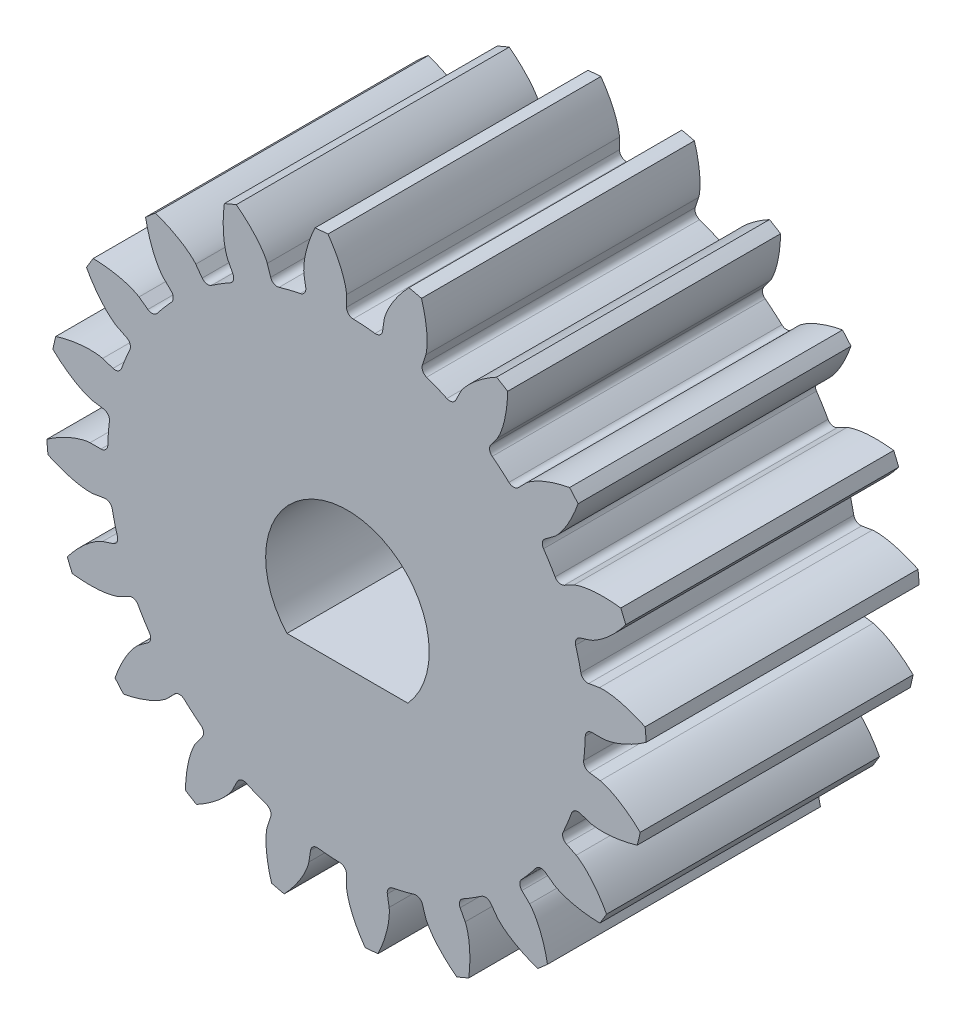
from build123d import *

# Parameters (mm, degrees)
BOSS_EXTRUDE3_DEPTH       = 5
FILLET1_R                 = 0.125
CIRPATTERN8_COUNT         = 20
CIRPATTERN8_COPY_1_DEPTH  = 5
CIRPATTERN8_COPY_2_DEPTH  = 5
CIRPATTERN8_COPY_3_DEPTH  = 5
CIRPATTERN8_COPY_4_DEPTH  = 5
CIRPATTERN8_COPY_5_DEPTH  = 5
CIRPATTERN8_COPY_6_DEPTH  = 5
CIRPATTERN8_COPY_7_DEPTH  = 5
CIRPATTERN8_COPY_8_DEPTH  = 5
CIRPATTERN8_COPY_9_DEPTH  = 5
CIRPATTERN8_COPY_10_DEPTH = 5
CIRPATTERN8_COPY_11_DEPTH = 5
CIRPATTERN8_COPY_12_DEPTH = 5
CIRPATTERN8_COPY_13_DEPTH = 5
CIRPATTERN8_COPY_14_DEPTH = 5
CIRPATTERN8_COPY_15_DEPTH = 5
CIRPATTERN8_COPY_16_DEPTH = 5
CIRPATTERN8_COPY_17_DEPTH = 5
CIRPATTERN8_COPY_18_DEPTH = 5
CIRPATTERN8_COPY_19_DEPTH = 5
FILLET1_OF_CIRPATTERN8_R  = 0.125
CUT_EXTRUDE2_DEPTH        = 6.0000001
TAGLIO_ESTRUSIONE2_DEPTH  = 0.3


with BuildPart() as part:
    # Sketch1 → Boss-Extrude3 (new body)
    with BuildSketch(Plane.XY):
        with BuildLine():
            Line((4.375, 0), (4.698463104, 0))
            add(Edge.make_bspline(
                [(4.698463104, 0), (4.701936693, 7.3507e-05), (4.711671667, 0.000507155), (4.730035453, 0.002224847), (4.759876783, 0.006298442), (4.79766874, 0.013349079), (4.846157716, 0.02458424), (4.902733795, 0.040529055), (4.964229103, 0.060864675), (5.030289125, 0.085989187), (5.095362708, 0.113680418), (5.159425932, 0.143715794), (5.222425493, 0.175792819), (5.297691656, 0.217156604), (5.372506382, 0.26189353), (5.430958883, 0.299810406), (5.473798774, 0.329094693), (5.489479816, 0.340016693)],
                knots=[0, 0, 0, 0, 0, 0.005376748, 0.015083688, 0.02853182, 0.046610139, 0.064854849, 0.092110525, 0.119476175, 0.146842495, 0.174208853, 0.201574955, 0.228941013, 0.256307345, 0.307035032, 0.336624535, 0.336624535, 0.336624535, 0.336624535, 0.336624535], degree=4))
            ThreePointArc((5.489479816, 0.340016693), (5.485490898, 0.399236281), (5.480863148, 0.458409374))
            Line((5.480863148, 0.458409374), (4.359777504, 0.36464382))
            ThreePointArc((4.359777504, 0.36464382), (4.371192719, 0.182480711), (4.375, 0))
        make_face()
        with BuildLine():
            ThreePointArc((-4.359777504, -0.36464382), (0.182480711, -4.371192719), (4.375, 0))
            ThreePointArc((4.375, 0), (4.371192719, 0.182480711), (4.359777504, 0.36464382))
            Line((4.359777504, 0.36464382), (-4.359777504, -0.36464382))
        make_face()
        with BuildLine():
            Line((-4.359777504, -0.36464382), (4.359777504, 0.36464382))
            ThreePointArc((4.359777504, 0.36464382), (-0.36464382, 4.359777504), (-4.359777504, -0.36464382))
        make_face()
    boss_extrude3 = extrude(amount=BOSS_EXTRUDE3_DEPTH)

    # Mirror2: Boss-Extrude3 across plane
    add(boss_extrude3.mirror(Plane(origin=(0, 0, 5), x_dir=(0, 0, 1), z_dir=(0.083347159, -0.996520572, 0))))

    # Fillet1
    fillet1_edges = [part.edges().sort_by_distance(p)[0] for p in [
        (4.375, 0, 2.5),
        (4.314215947, 0.726750137, 2.5),
    ]]
    fillet(fillet1_edges, radius=FILLET1_R)

    # CirPattern8: Boss-Extrude3 ×20 about axis
    cirpattern8_axis = Axis((0, 0, 5), (0, 0, -1))
    for i in range(1, CIRPATTERN8_COUNT):
        add(boss_extrude3.rotate(cirpattern8_axis, i * 360 / CIRPATTERN8_COUNT))

    # CirPattern8 copy 1 sketch → CirPattern8 copy 1 (add)
    with BuildSketch(Plane(origin=(0, 0, 0), x_dir=(0.989175162, -0.146739564, 0), z_dir=(0, 0, 1))):
        with BuildLine():
            Line((4.375, 0), (4.698463104, 0))
            add(Edge.make_bspline(
                [(4.698463104, 0), (4.701936693, -7.3507e-05), (4.711671667, -0.000507155), (4.730035453, -0.002224847), (4.759876783, -0.006298442), (4.79766874, -0.013349079), (4.846157716, -0.02458424), (4.902733795, -0.040529055), (4.964229103, -0.060864675), (5.030289125, -0.085989187), (5.095362708, -0.113680418), (5.159425932, -0.143715794), (5.222425493, -0.175792819), (5.297691656, -0.217156604), (5.372506382, -0.26189353), (5.430958883, -0.299810406), (5.473798774, -0.329094693), (5.489479816, -0.340016693)],
                knots=[0, 0, 0, 0, 0, 0.005376748, 0.015083688, 0.02853182, 0.046610139, 0.064854849, 0.092110525, 0.119476175, 0.146842495, 0.174208853, 0.201574955, 0.228941013, 0.256307345, 0.307035032, 0.336624535, 0.336624535, 0.336624535, 0.336624535, 0.336624535], degree=4))
            ThreePointArc((5.489479816, -0.340016693), (5.485490898, -0.399236281), (5.480863148, -0.458409374))
            Line((5.480863148, -0.458409374), (4.359777504, -0.36464382))
            ThreePointArc((4.359777504, -0.36464382), (4.371192719, -0.182480711), (4.375, 0))
        make_face()
        with BuildLine():
            ThreePointArc((-4.359777504, 0.36464382), (0.182480711, 4.371192719), (4.375, 0))
            ThreePointArc((4.375, 0), (4.371192719, -0.182480711), (4.359777504, -0.36464382))
            Line((4.359777504, -0.36464382), (-4.359777504, 0.36464382))
        make_face()
        with BuildLine():
            Line((-4.359777504, 0.36464382), (4.359777504, -0.36464382))
            ThreePointArc((4.359777504, -0.36464382), (-0.36464382, -4.359777504), (-4.359777504, 0.36464382))
        make_face()
    extrude(amount=CIRPATTERN8_COPY_1_DEPTH)

    # CirPattern8 copy 2 sketch → CirPattern8 copy 2 (add)
    with BuildSketch(Plane(origin=(0, 0, 0), x_dir=(0.895416464, -0.445229554, 0), z_dir=(0, 0, 1))):
        with BuildLine():
            Line((4.375, 0), (4.698463104, 0))
            add(Edge.make_bspline(
                [(4.698463104, 0), (4.701936693, -7.3507e-05), (4.711671667, -0.000507155), (4.730035453, -0.002224847), (4.759876783, -0.006298442), (4.79766874, -0.013349079), (4.846157716, -0.02458424), (4.902733795, -0.040529055), (4.964229103, -0.060864675), (5.030289125, -0.085989187), (5.095362708, -0.113680418), (5.159425932, -0.143715794), (5.222425493, -0.175792819), (5.297691656, -0.217156604), (5.372506382, -0.26189353), (5.430958883, -0.299810406), (5.473798774, -0.329094693), (5.489479816, -0.340016693)],
                knots=[0, 0, 0, 0, 0, 0.005376748, 0.015083688, 0.02853182, 0.046610139, 0.064854849, 0.092110525, 0.119476175, 0.146842495, 0.174208853, 0.201574955, 0.228941013, 0.256307345, 0.307035032, 0.336624535, 0.336624535, 0.336624535, 0.336624535, 0.336624535], degree=4))
            ThreePointArc((5.489479816, -0.340016693), (5.485490898, -0.399236281), (5.480863148, -0.458409374))
            Line((5.480863148, -0.458409374), (4.359777504, -0.36464382))
            ThreePointArc((4.359777504, -0.36464382), (4.371192719, -0.182480711), (4.375, 0))
        make_face()
        with BuildLine():
            ThreePointArc((-4.359777504, 0.36464382), (0.182480711, 4.371192719), (4.375, 0))
            ThreePointArc((4.375, 0), (4.371192719, -0.182480711), (4.359777504, -0.36464382))
            Line((4.359777504, -0.36464382), (-4.359777504, 0.36464382))
        make_face()
        with BuildLine():
            Line((-4.359777504, 0.36464382), (4.359777504, -0.36464382))
            ThreePointArc((4.359777504, -0.36464382), (-0.36464382, -4.359777504), (-4.359777504, 0.36464382))
        make_face()
    extrude(amount=CIRPATTERN8_COPY_2_DEPTH)

    # CirPattern8 copy 3 sketch → CirPattern8 copy 3 (add)
    with BuildSketch(Plane(origin=(0, 0, 0), x_dir=(0.714008165, -0.700137373, 0), z_dir=(0, 0, 1))):
        with BuildLine():
            Line((4.375, 0), (4.698463104, 0))
            add(Edge.make_bspline(
                [(4.698463104, 0), (4.701936693, -7.3507e-05), (4.711671667, -0.000507155), (4.730035453, -0.002224847), (4.759876783, -0.006298442), (4.79766874, -0.013349079), (4.846157716, -0.02458424), (4.902733795, -0.040529055), (4.964229103, -0.060864675), (5.030289125, -0.085989187), (5.095362708, -0.113680418), (5.159425932, -0.143715794), (5.222425493, -0.175792819), (5.297691656, -0.217156604), (5.372506382, -0.26189353), (5.430958883, -0.299810406), (5.473798774, -0.329094693), (5.489479816, -0.340016693)],
                knots=[0, 0, 0, 0, 0, 0.005376748, 0.015083688, 0.02853182, 0.046610139, 0.064854849, 0.092110525, 0.119476175, 0.146842495, 0.174208853, 0.201574955, 0.228941013, 0.256307345, 0.307035032, 0.336624535, 0.336624535, 0.336624535, 0.336624535, 0.336624535], degree=4))
            ThreePointArc((5.489479816, -0.340016693), (5.485490898, -0.399236281), (5.480863148, -0.458409374))
            Line((5.480863148, -0.458409374), (4.359777504, -0.36464382))
            ThreePointArc((4.359777504, -0.36464382), (4.371192719, -0.182480711), (4.375, 0))
        make_face()
        with BuildLine():
            ThreePointArc((-4.359777504, 0.36464382), (0.182480711, 4.371192719), (4.375, 0))
            ThreePointArc((4.375, 0), (4.371192719, -0.182480711), (4.359777504, -0.36464382))
            Line((4.359777504, -0.36464382), (-4.359777504, 0.36464382))
        make_face()
        with BuildLine():
            Line((-4.359777504, 0.36464382), (4.359777504, -0.36464382))
            ThreePointArc((4.359777504, -0.36464382), (-0.36464382, -4.359777504), (-4.359777504, 0.36464382))
        make_face()
    extrude(amount=CIRPATTERN8_COPY_3_DEPTH)

    # CirPattern8 copy 4 sketch → CirPattern8 copy 4 (add)
    with BuildSketch(Plane(origin=(0, 0, 0), x_dir=(0.462707771, -0.886510868, 0), z_dir=(0, 0, 1))):
        with BuildLine():
            Line((4.375, 0), (4.698463104, 0))
            add(Edge.make_bspline(
                [(4.698463104, 0), (4.701936693, -7.3507e-05), (4.711671667, -0.000507155), (4.730035453, -0.002224847), (4.759876783, -0.006298442), (4.79766874, -0.013349079), (4.846157716, -0.02458424), (4.902733795, -0.040529055), (4.964229103, -0.060864675), (5.030289125, -0.085989187), (5.095362708, -0.113680418), (5.159425932, -0.143715794), (5.222425493, -0.175792819), (5.297691656, -0.217156604), (5.372506382, -0.26189353), (5.430958883, -0.299810406), (5.473798774, -0.329094693), (5.489479816, -0.340016693)],
                knots=[0, 0, 0, 0, 0, 0.005376748, 0.015083688, 0.02853182, 0.046610139, 0.064854849, 0.092110525, 0.119476175, 0.146842495, 0.174208853, 0.201574955, 0.228941013, 0.256307345, 0.307035032, 0.336624535, 0.336624535, 0.336624535, 0.336624535, 0.336624535], degree=4))
            ThreePointArc((5.489479816, -0.340016693), (5.485490898, -0.399236281), (5.480863148, -0.458409374))
            Line((5.480863148, -0.458409374), (4.359777504, -0.36464382))
            ThreePointArc((4.359777504, -0.36464382), (4.371192719, -0.182480711), (4.375, 0))
        make_face()
        with BuildLine():
            ThreePointArc((-4.359777504, 0.36464382), (0.182480711, 4.371192719), (4.375, 0))
            ThreePointArc((4.375, 0), (4.371192719, -0.182480711), (4.359777504, -0.36464382))
            Line((4.359777504, -0.36464382), (-4.359777504, 0.36464382))
        make_face()
        with BuildLine():
            Line((-4.359777504, 0.36464382), (4.359777504, -0.36464382))
            ThreePointArc((4.359777504, -0.36464382), (-0.36464382, -4.359777504), (-4.359777504, 0.36464382))
        make_face()
    extrude(amount=CIRPATTERN8_COPY_4_DEPTH)

    # CirPattern8 copy 5 sketch → CirPattern8 copy 5 (add)
    with BuildSketch(Plane(origin=(0, 0, 0), x_dir=(0.166114317, -0.986106502, 0), z_dir=(0, 0, 1))):
        with BuildLine():
            Line((4.375, 0), (4.698463104, 0))
            add(Edge.make_bspline(
                [(4.698463104, 0), (4.701936693, -7.3507e-05), (4.711671667, -0.000507155), (4.730035453, -0.002224847), (4.759876783, -0.006298442), (4.79766874, -0.013349079), (4.846157716, -0.02458424), (4.902733795, -0.040529055), (4.964229103, -0.060864675), (5.030289125, -0.085989187), (5.095362708, -0.113680418), (5.159425932, -0.143715794), (5.222425493, -0.175792819), (5.297691656, -0.217156604), (5.372506382, -0.26189353), (5.430958883, -0.299810406), (5.473798774, -0.329094693), (5.489479816, -0.340016693)],
                knots=[0, 0, 0, 0, 0, 0.005376748, 0.015083688, 0.02853182, 0.046610139, 0.064854849, 0.092110525, 0.119476175, 0.146842495, 0.174208853, 0.201574955, 0.228941013, 0.256307345, 0.307035032, 0.336624535, 0.336624535, 0.336624535, 0.336624535, 0.336624535], degree=4))
            ThreePointArc((5.489479816, -0.340016693), (5.485490898, -0.399236281), (5.480863148, -0.458409374))
            Line((5.480863148, -0.458409374), (4.359777504, -0.36464382))
            ThreePointArc((4.359777504, -0.36464382), (4.371192719, -0.182480711), (4.375, 0))
        make_face()
        with BuildLine():
            ThreePointArc((-4.359777504, 0.36464382), (0.182480711, 4.371192719), (4.375, 0))
            ThreePointArc((4.375, 0), (4.371192719, -0.182480711), (4.359777504, -0.36464382))
            Line((4.359777504, -0.36464382), (-4.359777504, 0.36464382))
        make_face()
        with BuildLine():
            Line((-4.359777504, 0.36464382), (4.359777504, -0.36464382))
            ThreePointArc((4.359777504, -0.36464382), (-0.36464382, -4.359777504), (-4.359777504, 0.36464382))
        make_face()
    extrude(amount=CIRPATTERN8_COPY_5_DEPTH)

    # CirPattern8 copy 6 sketch → CirPattern8 copy 6 (add)
    with BuildSketch(Plane(origin=(0, 0, 0), x_dir=(-0.146739564, -0.989175162, 0), z_dir=(0, 0, 1))):
        with BuildLine():
            Line((4.375, 0), (4.698463104, 0))
            add(Edge.make_bspline(
                [(4.698463104, 0), (4.701936693, -7.3507e-05), (4.711671667, -0.000507155), (4.730035453, -0.002224847), (4.759876783, -0.006298442), (4.79766874, -0.013349079), (4.846157716, -0.02458424), (4.902733795, -0.040529055), (4.964229103, -0.060864675), (5.030289125, -0.085989187), (5.095362708, -0.113680418), (5.159425932, -0.143715794), (5.222425493, -0.175792819), (5.297691656, -0.217156604), (5.372506382, -0.26189353), (5.430958883, -0.299810406), (5.473798774, -0.329094693), (5.489479816, -0.340016693)],
                knots=[0, 0, 0, 0, 0, 0.005376748, 0.015083688, 0.02853182, 0.046610139, 0.064854849, 0.092110525, 0.119476175, 0.146842495, 0.174208853, 0.201574955, 0.228941013, 0.256307345, 0.307035032, 0.336624535, 0.336624535, 0.336624535, 0.336624535, 0.336624535], degree=4))
            ThreePointArc((5.489479816, -0.340016693), (5.485490898, -0.399236281), (5.480863148, -0.458409374))
            Line((5.480863148, -0.458409374), (4.359777504, -0.36464382))
            ThreePointArc((4.359777504, -0.36464382), (4.371192719, -0.182480711), (4.375, 0))
        make_face()
        with BuildLine():
            ThreePointArc((-4.359777504, 0.36464382), (0.182480711, 4.371192719), (4.375, 0))
            ThreePointArc((4.375, 0), (4.371192719, -0.182480711), (4.359777504, -0.36464382))
            Line((4.359777504, -0.36464382), (-4.359777504, 0.36464382))
        make_face()
        with BuildLine():
            Line((-4.359777504, 0.36464382), (4.359777504, -0.36464382))
            ThreePointArc((4.359777504, -0.36464382), (-0.36464382, -4.359777504), (-4.359777504, 0.36464382))
        make_face()
    extrude(amount=CIRPATTERN8_COPY_6_DEPTH)

    # CirPattern8 copy 7 sketch → CirPattern8 copy 7 (add)
    with BuildSketch(Plane(origin=(0, 0, 0), x_dir=(-0.445229554, -0.895416464, 0), z_dir=(0, 0, 1))):
        with BuildLine():
            Line((4.375, 0), (4.698463104, 0))
            add(Edge.make_bspline(
                [(4.698463104, 0), (4.701936693, -7.3507e-05), (4.711671667, -0.000507155), (4.730035453, -0.002224847), (4.759876783, -0.006298442), (4.79766874, -0.013349079), (4.846157716, -0.02458424), (4.902733795, -0.040529055), (4.964229103, -0.060864675), (5.030289125, -0.085989187), (5.095362708, -0.113680418), (5.159425932, -0.143715794), (5.222425493, -0.175792819), (5.297691656, -0.217156604), (5.372506382, -0.26189353), (5.430958883, -0.299810406), (5.473798774, -0.329094693), (5.489479816, -0.340016693)],
                knots=[0, 0, 0, 0, 0, 0.005376748, 0.015083688, 0.02853182, 0.046610139, 0.064854849, 0.092110525, 0.119476175, 0.146842495, 0.174208853, 0.201574955, 0.228941013, 0.256307345, 0.307035032, 0.336624535, 0.336624535, 0.336624535, 0.336624535, 0.336624535], degree=4))
            ThreePointArc((5.489479816, -0.340016693), (5.485490898, -0.399236281), (5.480863148, -0.458409374))
            Line((5.480863148, -0.458409374), (4.359777504, -0.36464382))
            ThreePointArc((4.359777504, -0.36464382), (4.371192719, -0.182480711), (4.375, 0))
        make_face()
        with BuildLine():
            ThreePointArc((-4.359777504, 0.36464382), (0.182480711, 4.371192719), (4.375, 0))
            ThreePointArc((4.375, 0), (4.371192719, -0.182480711), (4.359777504, -0.36464382))
            Line((4.359777504, -0.36464382), (-4.359777504, 0.36464382))
        make_face()
        with BuildLine():
            Line((-4.359777504, 0.36464382), (4.359777504, -0.36464382))
            ThreePointArc((4.359777504, -0.36464382), (-0.36464382, -4.359777504), (-4.359777504, 0.36464382))
        make_face()
    extrude(amount=CIRPATTERN8_COPY_7_DEPTH)

    # CirPattern8 copy 8 sketch → CirPattern8 copy 8 (add)
    with BuildSketch(Plane(origin=(0, 0, 0), x_dir=(-0.700137373, -0.714008165, 0), z_dir=(0, 0, 1))):
        with BuildLine():
            Line((4.375, 0), (4.698463104, 0))
            add(Edge.make_bspline(
                [(4.698463104, 0), (4.701936693, -7.3507e-05), (4.711671667, -0.000507155), (4.730035453, -0.002224847), (4.759876783, -0.006298442), (4.79766874, -0.013349079), (4.846157716, -0.02458424), (4.902733795, -0.040529055), (4.964229103, -0.060864675), (5.030289125, -0.085989187), (5.095362708, -0.113680418), (5.159425932, -0.143715794), (5.222425493, -0.175792819), (5.297691656, -0.217156604), (5.372506382, -0.26189353), (5.430958883, -0.299810406), (5.473798774, -0.329094693), (5.489479816, -0.340016693)],
                knots=[0, 0, 0, 0, 0, 0.005376748, 0.015083688, 0.02853182, 0.046610139, 0.064854849, 0.092110525, 0.119476175, 0.146842495, 0.174208853, 0.201574955, 0.228941013, 0.256307345, 0.307035032, 0.336624535, 0.336624535, 0.336624535, 0.336624535, 0.336624535], degree=4))
            ThreePointArc((5.489479816, -0.340016693), (5.485490898, -0.399236281), (5.480863148, -0.458409374))
            Line((5.480863148, -0.458409374), (4.359777504, -0.36464382))
            ThreePointArc((4.359777504, -0.36464382), (4.371192719, -0.182480711), (4.375, 0))
        make_face()
        with BuildLine():
            ThreePointArc((-4.359777504, 0.36464382), (0.182480711, 4.371192719), (4.375, 0))
            ThreePointArc((4.375, 0), (4.371192719, -0.182480711), (4.359777504, -0.36464382))
            Line((4.359777504, -0.36464382), (-4.359777504, 0.36464382))
        make_face()
        with BuildLine():
            Line((-4.359777504, 0.36464382), (4.359777504, -0.36464382))
            ThreePointArc((4.359777504, -0.36464382), (-0.36464382, -4.359777504), (-4.359777504, 0.36464382))
        make_face()
    extrude(amount=CIRPATTERN8_COPY_8_DEPTH)

    # CirPattern8 copy 9 sketch → CirPattern8 copy 9 (add)
    with BuildSketch(Plane(origin=(0, 0, 0), x_dir=(-0.886510868, -0.462707771, 0), z_dir=(0, 0, 1))):
        with BuildLine():
            Line((4.375, 0), (4.698463104, 0))
            add(Edge.make_bspline(
                [(4.698463104, 0), (4.701936693, -7.3507e-05), (4.711671667, -0.000507155), (4.730035453, -0.002224847), (4.759876783, -0.006298442), (4.79766874, -0.013349079), (4.846157716, -0.02458424), (4.902733795, -0.040529055), (4.964229103, -0.060864675), (5.030289125, -0.085989187), (5.095362708, -0.113680418), (5.159425932, -0.143715794), (5.222425493, -0.175792819), (5.297691656, -0.217156604), (5.372506382, -0.26189353), (5.430958883, -0.299810406), (5.473798774, -0.329094693), (5.489479816, -0.340016693)],
                knots=[0, 0, 0, 0, 0, 0.005376748, 0.015083688, 0.02853182, 0.046610139, 0.064854849, 0.092110525, 0.119476175, 0.146842495, 0.174208853, 0.201574955, 0.228941013, 0.256307345, 0.307035032, 0.336624535, 0.336624535, 0.336624535, 0.336624535, 0.336624535], degree=4))
            ThreePointArc((5.489479816, -0.340016693), (5.485490898, -0.399236281), (5.480863148, -0.458409374))
            Line((5.480863148, -0.458409374), (4.359777504, -0.36464382))
            ThreePointArc((4.359777504, -0.36464382), (4.371192719, -0.182480711), (4.375, 0))
        make_face()
        with BuildLine():
            ThreePointArc((-4.359777504, 0.36464382), (0.182480711, 4.371192719), (4.375, 0))
            ThreePointArc((4.375, 0), (4.371192719, -0.182480711), (4.359777504, -0.36464382))
            Line((4.359777504, -0.36464382), (-4.359777504, 0.36464382))
        make_face()
        with BuildLine():
            Line((-4.359777504, 0.36464382), (4.359777504, -0.36464382))
            ThreePointArc((4.359777504, -0.36464382), (-0.36464382, -4.359777504), (-4.359777504, 0.36464382))
        make_face()
    extrude(amount=CIRPATTERN8_COPY_9_DEPTH)

    # CirPattern8 copy 10 sketch → CirPattern8 copy 10 (add)
    with BuildSketch(Plane(origin=(0, 0, 0), x_dir=(-0.986106502, -0.166114317, 0), z_dir=(0, 0, 1))):
        with BuildLine():
            Line((4.375, 0), (4.698463104, 0))
            add(Edge.make_bspline(
                [(4.698463104, 0), (4.701936693, -7.3507e-05), (4.711671667, -0.000507155), (4.730035453, -0.002224847), (4.759876783, -0.006298442), (4.79766874, -0.013349079), (4.846157716, -0.02458424), (4.902733795, -0.040529055), (4.964229103, -0.060864675), (5.030289125, -0.085989187), (5.095362708, -0.113680418), (5.159425932, -0.143715794), (5.222425493, -0.175792819), (5.297691656, -0.217156604), (5.372506382, -0.26189353), (5.430958883, -0.299810406), (5.473798774, -0.329094693), (5.489479816, -0.340016693)],
                knots=[0, 0, 0, 0, 0, 0.005376748, 0.015083688, 0.02853182, 0.046610139, 0.064854849, 0.092110525, 0.119476175, 0.146842495, 0.174208853, 0.201574955, 0.228941013, 0.256307345, 0.307035032, 0.336624535, 0.336624535, 0.336624535, 0.336624535, 0.336624535], degree=4))
            ThreePointArc((5.489479816, -0.340016693), (5.485490898, -0.399236281), (5.480863148, -0.458409374))
            Line((5.480863148, -0.458409374), (4.359777504, -0.36464382))
            ThreePointArc((4.359777504, -0.36464382), (4.371192719, -0.182480711), (4.375, 0))
        make_face()
        with BuildLine():
            ThreePointArc((-4.359777504, 0.36464382), (0.182480711, 4.371192719), (4.375, 0))
            ThreePointArc((4.375, 0), (4.371192719, -0.182480711), (4.359777504, -0.36464382))
            Line((4.359777504, -0.36464382), (-4.359777504, 0.36464382))
        make_face()
        with BuildLine():
            Line((-4.359777504, 0.36464382), (4.359777504, -0.36464382))
            ThreePointArc((4.359777504, -0.36464382), (-0.36464382, -4.359777504), (-4.359777504, 0.36464382))
        make_face()
    extrude(amount=CIRPATTERN8_COPY_10_DEPTH)

    # CirPattern8 copy 11 sketch → CirPattern8 copy 11 (add)
    with BuildSketch(Plane(origin=(0, 0, 0), x_dir=(-0.989175162, 0.146739564, 0), z_dir=(0, 0, 1))):
        with BuildLine():
            Line((4.375, 0), (4.698463104, 0))
            add(Edge.make_bspline(
                [(4.698463104, 0), (4.701936693, -7.3507e-05), (4.711671667, -0.000507155), (4.730035453, -0.002224847), (4.759876783, -0.006298442), (4.79766874, -0.013349079), (4.846157716, -0.02458424), (4.902733795, -0.040529055), (4.964229103, -0.060864675), (5.030289125, -0.085989187), (5.095362708, -0.113680418), (5.159425932, -0.143715794), (5.222425493, -0.175792819), (5.297691656, -0.217156604), (5.372506382, -0.26189353), (5.430958883, -0.299810406), (5.473798774, -0.329094693), (5.489479816, -0.340016693)],
                knots=[0, 0, 0, 0, 0, 0.005376748, 0.015083688, 0.02853182, 0.046610139, 0.064854849, 0.092110525, 0.119476175, 0.146842495, 0.174208853, 0.201574955, 0.228941013, 0.256307345, 0.307035032, 0.336624535, 0.336624535, 0.336624535, 0.336624535, 0.336624535], degree=4))
            ThreePointArc((5.489479816, -0.340016693), (5.485490898, -0.399236281), (5.480863148, -0.458409374))
            Line((5.480863148, -0.458409374), (4.359777504, -0.36464382))
            ThreePointArc((4.359777504, -0.36464382), (4.371192719, -0.182480711), (4.375, 0))
        make_face()
        with BuildLine():
            ThreePointArc((-4.359777504, 0.36464382), (0.182480711, 4.371192719), (4.375, 0))
            ThreePointArc((4.375, 0), (4.371192719, -0.182480711), (4.359777504, -0.36464382))
            Line((4.359777504, -0.36464382), (-4.359777504, 0.36464382))
        make_face()
        with BuildLine():
            Line((-4.359777504, 0.36464382), (4.359777504, -0.36464382))
            ThreePointArc((4.359777504, -0.36464382), (-0.36464382, -4.359777504), (-4.359777504, 0.36464382))
        make_face()
    extrude(amount=CIRPATTERN8_COPY_11_DEPTH)

    # CirPattern8 copy 12 sketch → CirPattern8 copy 12 (add)
    with BuildSketch(Plane(origin=(0, 0, 0), x_dir=(-0.895416464, 0.445229554, 0), z_dir=(0, 0, 1))):
        with BuildLine():
            Line((4.375, 0), (4.698463104, 0))
            add(Edge.make_bspline(
                [(4.698463104, 0), (4.701936693, -7.3507e-05), (4.711671667, -0.000507155), (4.730035453, -0.002224847), (4.759876783, -0.006298442), (4.79766874, -0.013349079), (4.846157716, -0.02458424), (4.902733795, -0.040529055), (4.964229103, -0.060864675), (5.030289125, -0.085989187), (5.095362708, -0.113680418), (5.159425932, -0.143715794), (5.222425493, -0.175792819), (5.297691656, -0.217156604), (5.372506382, -0.26189353), (5.430958883, -0.299810406), (5.473798774, -0.329094693), (5.489479816, -0.340016693)],
                knots=[0, 0, 0, 0, 0, 0.005376748, 0.015083688, 0.02853182, 0.046610139, 0.064854849, 0.092110525, 0.119476175, 0.146842495, 0.174208853, 0.201574955, 0.228941013, 0.256307345, 0.307035032, 0.336624535, 0.336624535, 0.336624535, 0.336624535, 0.336624535], degree=4))
            ThreePointArc((5.489479816, -0.340016693), (5.485490898, -0.399236281), (5.480863148, -0.458409374))
            Line((5.480863148, -0.458409374), (4.359777504, -0.36464382))
            ThreePointArc((4.359777504, -0.36464382), (4.371192719, -0.182480711), (4.375, 0))
        make_face()
        with BuildLine():
            ThreePointArc((-4.359777504, 0.36464382), (0.182480711, 4.371192719), (4.375, 0))
            ThreePointArc((4.375, 0), (4.371192719, -0.182480711), (4.359777504, -0.36464382))
            Line((4.359777504, -0.36464382), (-4.359777504, 0.36464382))
        make_face()
        with BuildLine():
            Line((-4.359777504, 0.36464382), (4.359777504, -0.36464382))
            ThreePointArc((4.359777504, -0.36464382), (-0.36464382, -4.359777504), (-4.359777504, 0.36464382))
        make_face()
    extrude(amount=CIRPATTERN8_COPY_12_DEPTH)

    # CirPattern8 copy 13 sketch → CirPattern8 copy 13 (add)
    with BuildSketch(Plane(origin=(0, 0, 0), x_dir=(-0.714008165, 0.700137373, 0), z_dir=(0, 0, 1))):
        with BuildLine():
            Line((4.375, 0), (4.698463104, 0))
            add(Edge.make_bspline(
                [(4.698463104, 0), (4.701936693, -7.3507e-05), (4.711671667, -0.000507155), (4.730035453, -0.002224847), (4.759876783, -0.006298442), (4.79766874, -0.013349079), (4.846157716, -0.02458424), (4.902733795, -0.040529055), (4.964229103, -0.060864675), (5.030289125, -0.085989187), (5.095362708, -0.113680418), (5.159425932, -0.143715794), (5.222425493, -0.175792819), (5.297691656, -0.217156604), (5.372506382, -0.26189353), (5.430958883, -0.299810406), (5.473798774, -0.329094693), (5.489479816, -0.340016693)],
                knots=[0, 0, 0, 0, 0, 0.005376748, 0.015083688, 0.02853182, 0.046610139, 0.064854849, 0.092110525, 0.119476175, 0.146842495, 0.174208853, 0.201574955, 0.228941013, 0.256307345, 0.307035032, 0.336624535, 0.336624535, 0.336624535, 0.336624535, 0.336624535], degree=4))
            ThreePointArc((5.489479816, -0.340016693), (5.485490898, -0.399236281), (5.480863148, -0.458409374))
            Line((5.480863148, -0.458409374), (4.359777504, -0.36464382))
            ThreePointArc((4.359777504, -0.36464382), (4.371192719, -0.182480711), (4.375, 0))
        make_face()
        with BuildLine():
            ThreePointArc((-4.359777504, 0.36464382), (0.182480711, 4.371192719), (4.375, 0))
            ThreePointArc((4.375, 0), (4.371192719, -0.182480711), (4.359777504, -0.36464382))
            Line((4.359777504, -0.36464382), (-4.359777504, 0.36464382))
        make_face()
        with BuildLine():
            Line((-4.359777504, 0.36464382), (4.359777504, -0.36464382))
            ThreePointArc((4.359777504, -0.36464382), (-0.36464382, -4.359777504), (-4.359777504, 0.36464382))
        make_face()
    extrude(amount=CIRPATTERN8_COPY_13_DEPTH)

    # CirPattern8 copy 14 sketch → CirPattern8 copy 14 (add)
    with BuildSketch(Plane(origin=(0, 0, 0), x_dir=(-0.462707771, 0.886510868, 0), z_dir=(0, 0, 1))):
        with BuildLine():
            Line((4.375, 0), (4.698463104, 0))
            add(Edge.make_bspline(
                [(4.698463104, 0), (4.701936693, -7.3507e-05), (4.711671667, -0.000507155), (4.730035453, -0.002224847), (4.759876783, -0.006298442), (4.79766874, -0.013349079), (4.846157716, -0.02458424), (4.902733795, -0.040529055), (4.964229103, -0.060864675), (5.030289125, -0.085989187), (5.095362708, -0.113680418), (5.159425932, -0.143715794), (5.222425493, -0.175792819), (5.297691656, -0.217156604), (5.372506382, -0.26189353), (5.430958883, -0.299810406), (5.473798774, -0.329094693), (5.489479816, -0.340016693)],
                knots=[0, 0, 0, 0, 0, 0.005376748, 0.015083688, 0.02853182, 0.046610139, 0.064854849, 0.092110525, 0.119476175, 0.146842495, 0.174208853, 0.201574955, 0.228941013, 0.256307345, 0.307035032, 0.336624535, 0.336624535, 0.336624535, 0.336624535, 0.336624535], degree=4))
            ThreePointArc((5.489479816, -0.340016693), (5.485490898, -0.399236281), (5.480863148, -0.458409374))
            Line((5.480863148, -0.458409374), (4.359777504, -0.36464382))
            ThreePointArc((4.359777504, -0.36464382), (4.371192719, -0.182480711), (4.375, 0))
        make_face()
        with BuildLine():
            ThreePointArc((-4.359777504, 0.36464382), (0.182480711, 4.371192719), (4.375, 0))
            ThreePointArc((4.375, 0), (4.371192719, -0.182480711), (4.359777504, -0.36464382))
            Line((4.359777504, -0.36464382), (-4.359777504, 0.36464382))
        make_face()
        with BuildLine():
            Line((-4.359777504, 0.36464382), (4.359777504, -0.36464382))
            ThreePointArc((4.359777504, -0.36464382), (-0.36464382, -4.359777504), (-4.359777504, 0.36464382))
        make_face()
    extrude(amount=CIRPATTERN8_COPY_14_DEPTH)

    # CirPattern8 copy 15 sketch → CirPattern8 copy 15 (add)
    with BuildSketch(Plane(origin=(0, 0, 0), x_dir=(-0.166114317, 0.986106502, 0), z_dir=(0, 0, 1))):
        with BuildLine():
            Line((4.375, 0), (4.698463104, 0))
            add(Edge.make_bspline(
                [(4.698463104, 0), (4.701936693, -7.3507e-05), (4.711671667, -0.000507155), (4.730035453, -0.002224847), (4.759876783, -0.006298442), (4.79766874, -0.013349079), (4.846157716, -0.02458424), (4.902733795, -0.040529055), (4.964229103, -0.060864675), (5.030289125, -0.085989187), (5.095362708, -0.113680418), (5.159425932, -0.143715794), (5.222425493, -0.175792819), (5.297691656, -0.217156604), (5.372506382, -0.26189353), (5.430958883, -0.299810406), (5.473798774, -0.329094693), (5.489479816, -0.340016693)],
                knots=[0, 0, 0, 0, 0, 0.005376748, 0.015083688, 0.02853182, 0.046610139, 0.064854849, 0.092110525, 0.119476175, 0.146842495, 0.174208853, 0.201574955, 0.228941013, 0.256307345, 0.307035032, 0.336624535, 0.336624535, 0.336624535, 0.336624535, 0.336624535], degree=4))
            ThreePointArc((5.489479816, -0.340016693), (5.485490898, -0.399236281), (5.480863148, -0.458409374))
            Line((5.480863148, -0.458409374), (4.359777504, -0.36464382))
            ThreePointArc((4.359777504, -0.36464382), (4.371192719, -0.182480711), (4.375, 0))
        make_face()
        with BuildLine():
            ThreePointArc((-4.359777504, 0.36464382), (0.182480711, 4.371192719), (4.375, 0))
            ThreePointArc((4.375, 0), (4.371192719, -0.182480711), (4.359777504, -0.36464382))
            Line((4.359777504, -0.36464382), (-4.359777504, 0.36464382))
        make_face()
        with BuildLine():
            Line((-4.359777504, 0.36464382), (4.359777504, -0.36464382))
            ThreePointArc((4.359777504, -0.36464382), (-0.36464382, -4.359777504), (-4.359777504, 0.36464382))
        make_face()
    extrude(amount=CIRPATTERN8_COPY_15_DEPTH)

    # CirPattern8 copy 16 sketch → CirPattern8 copy 16 (add)
    with BuildSketch(Plane(origin=(0, 0, 0), x_dir=(0.146739564, 0.989175162, 0), z_dir=(0, 0, 1))):
        with BuildLine():
            Line((4.375, 0), (4.698463104, 0))
            add(Edge.make_bspline(
                [(4.698463104, 0), (4.701936693, -7.3507e-05), (4.711671667, -0.000507155), (4.730035453, -0.002224847), (4.759876783, -0.006298442), (4.79766874, -0.013349079), (4.846157716, -0.02458424), (4.902733795, -0.040529055), (4.964229103, -0.060864675), (5.030289125, -0.085989187), (5.095362708, -0.113680418), (5.159425932, -0.143715794), (5.222425493, -0.175792819), (5.297691656, -0.217156604), (5.372506382, -0.26189353), (5.430958883, -0.299810406), (5.473798774, -0.329094693), (5.489479816, -0.340016693)],
                knots=[0, 0, 0, 0, 0, 0.005376748, 0.015083688, 0.02853182, 0.046610139, 0.064854849, 0.092110525, 0.119476175, 0.146842495, 0.174208853, 0.201574955, 0.228941013, 0.256307345, 0.307035032, 0.336624535, 0.336624535, 0.336624535, 0.336624535, 0.336624535], degree=4))
            ThreePointArc((5.489479816, -0.340016693), (5.485490898, -0.399236281), (5.480863148, -0.458409374))
            Line((5.480863148, -0.458409374), (4.359777504, -0.36464382))
            ThreePointArc((4.359777504, -0.36464382), (4.371192719, -0.182480711), (4.375, 0))
        make_face()
        with BuildLine():
            ThreePointArc((-4.359777504, 0.36464382), (0.182480711, 4.371192719), (4.375, 0))
            ThreePointArc((4.375, 0), (4.371192719, -0.182480711), (4.359777504, -0.36464382))
            Line((4.359777504, -0.36464382), (-4.359777504, 0.36464382))
        make_face()
        with BuildLine():
            Line((-4.359777504, 0.36464382), (4.359777504, -0.36464382))
            ThreePointArc((4.359777504, -0.36464382), (-0.36464382, -4.359777504), (-4.359777504, 0.36464382))
        make_face()
    extrude(amount=CIRPATTERN8_COPY_16_DEPTH)

    # CirPattern8 copy 17 sketch → CirPattern8 copy 17 (add)
    with BuildSketch(Plane(origin=(0, 0, 0), x_dir=(0.445229554, 0.895416464, 0), z_dir=(0, 0, 1))):
        with BuildLine():
            Line((4.375, 0), (4.698463104, 0))
            add(Edge.make_bspline(
                [(4.698463104, 0), (4.701936693, -7.3507e-05), (4.711671667, -0.000507155), (4.730035453, -0.002224847), (4.759876783, -0.006298442), (4.79766874, -0.013349079), (4.846157716, -0.02458424), (4.902733795, -0.040529055), (4.964229103, -0.060864675), (5.030289125, -0.085989187), (5.095362708, -0.113680418), (5.159425932, -0.143715794), (5.222425493, -0.175792819), (5.297691656, -0.217156604), (5.372506382, -0.26189353), (5.430958883, -0.299810406), (5.473798774, -0.329094693), (5.489479816, -0.340016693)],
                knots=[0, 0, 0, 0, 0, 0.005376748, 0.015083688, 0.02853182, 0.046610139, 0.064854849, 0.092110525, 0.119476175, 0.146842495, 0.174208853, 0.201574955, 0.228941013, 0.256307345, 0.307035032, 0.336624535, 0.336624535, 0.336624535, 0.336624535, 0.336624535], degree=4))
            ThreePointArc((5.489479816, -0.340016693), (5.485490898, -0.399236281), (5.480863148, -0.458409374))
            Line((5.480863148, -0.458409374), (4.359777504, -0.36464382))
            ThreePointArc((4.359777504, -0.36464382), (4.371192719, -0.182480711), (4.375, 0))
        make_face()
        with BuildLine():
            ThreePointArc((-4.359777504, 0.36464382), (0.182480711, 4.371192719), (4.375, 0))
            ThreePointArc((4.375, 0), (4.371192719, -0.182480711), (4.359777504, -0.36464382))
            Line((4.359777504, -0.36464382), (-4.359777504, 0.36464382))
        make_face()
        with BuildLine():
            Line((-4.359777504, 0.36464382), (4.359777504, -0.36464382))
            ThreePointArc((4.359777504, -0.36464382), (-0.36464382, -4.359777504), (-4.359777504, 0.36464382))
        make_face()
    extrude(amount=CIRPATTERN8_COPY_17_DEPTH)

    # CirPattern8 copy 18 sketch → CirPattern8 copy 18 (add)
    with BuildSketch(Plane(origin=(0, 0, 0), x_dir=(0.700137373, 0.714008165, 0), z_dir=(0, 0, 1))):
        with BuildLine():
            Line((4.375, 0), (4.698463104, 0))
            add(Edge.make_bspline(
                [(4.698463104, 0), (4.701936693, -7.3507e-05), (4.711671667, -0.000507155), (4.730035453, -0.002224847), (4.759876783, -0.006298442), (4.79766874, -0.013349079), (4.846157716, -0.02458424), (4.902733795, -0.040529055), (4.964229103, -0.060864675), (5.030289125, -0.085989187), (5.095362708, -0.113680418), (5.159425932, -0.143715794), (5.222425493, -0.175792819), (5.297691656, -0.217156604), (5.372506382, -0.26189353), (5.430958883, -0.299810406), (5.473798774, -0.329094693), (5.489479816, -0.340016693)],
                knots=[0, 0, 0, 0, 0, 0.005376748, 0.015083688, 0.02853182, 0.046610139, 0.064854849, 0.092110525, 0.119476175, 0.146842495, 0.174208853, 0.201574955, 0.228941013, 0.256307345, 0.307035032, 0.336624535, 0.336624535, 0.336624535, 0.336624535, 0.336624535], degree=4))
            ThreePointArc((5.489479816, -0.340016693), (5.485490898, -0.399236281), (5.480863148, -0.458409374))
            Line((5.480863148, -0.458409374), (4.359777504, -0.36464382))
            ThreePointArc((4.359777504, -0.36464382), (4.371192719, -0.182480711), (4.375, 0))
        make_face()
        with BuildLine():
            ThreePointArc((-4.359777504, 0.36464382), (0.182480711, 4.371192719), (4.375, 0))
            ThreePointArc((4.375, 0), (4.371192719, -0.182480711), (4.359777504, -0.36464382))
            Line((4.359777504, -0.36464382), (-4.359777504, 0.36464382))
        make_face()
        with BuildLine():
            Line((-4.359777504, 0.36464382), (4.359777504, -0.36464382))
            ThreePointArc((4.359777504, -0.36464382), (-0.36464382, -4.359777504), (-4.359777504, 0.36464382))
        make_face()
    extrude(amount=CIRPATTERN8_COPY_18_DEPTH)

    # CirPattern8 copy 19 sketch → CirPattern8 copy 19 (add)
    with BuildSketch(Plane(origin=(0, 0, 0), x_dir=(0.886510868, 0.462707771, 0), z_dir=(0, 0, 1))):
        with BuildLine():
            Line((4.375, 0), (4.698463104, 0))
            add(Edge.make_bspline(
                [(4.698463104, 0), (4.701936693, -7.3507e-05), (4.711671667, -0.000507155), (4.730035453, -0.002224847), (4.759876783, -0.006298442), (4.79766874, -0.013349079), (4.846157716, -0.02458424), (4.902733795, -0.040529055), (4.964229103, -0.060864675), (5.030289125, -0.085989187), (5.095362708, -0.113680418), (5.159425932, -0.143715794), (5.222425493, -0.175792819), (5.297691656, -0.217156604), (5.372506382, -0.26189353), (5.430958883, -0.299810406), (5.473798774, -0.329094693), (5.489479816, -0.340016693)],
                knots=[0, 0, 0, 0, 0, 0.005376748, 0.015083688, 0.02853182, 0.046610139, 0.064854849, 0.092110525, 0.119476175, 0.146842495, 0.174208853, 0.201574955, 0.228941013, 0.256307345, 0.307035032, 0.336624535, 0.336624535, 0.336624535, 0.336624535, 0.336624535], degree=4))
            ThreePointArc((5.489479816, -0.340016693), (5.485490898, -0.399236281), (5.480863148, -0.458409374))
            Line((5.480863148, -0.458409374), (4.359777504, -0.36464382))
            ThreePointArc((4.359777504, -0.36464382), (4.371192719, -0.182480711), (4.375, 0))
        make_face()
        with BuildLine():
            ThreePointArc((-4.359777504, 0.36464382), (0.182480711, 4.371192719), (4.375, 0))
            ThreePointArc((4.375, 0), (4.371192719, -0.182480711), (4.359777504, -0.36464382))
            Line((4.359777504, -0.36464382), (-4.359777504, 0.36464382))
        make_face()
        with BuildLine():
            Line((-4.359777504, 0.36464382), (4.359777504, -0.36464382))
            ThreePointArc((4.359777504, -0.36464382), (-0.36464382, -4.359777504), (-4.359777504, 0.36464382))
        make_face()
    extrude(amount=CIRPATTERN8_COPY_19_DEPTH)

    # Fillet1 of CirPattern8
    fillet1_of_cirpattern8_edges = [part.edges().sort_by_distance(p)[0] for p in [
        (4.160872259, -1.35194935, 2.5),
        (4.327641332, -0.641985591, 2.5),
        (3.53944935, -2.571560479, 2.5),
        (3.917447031, -1.947879297, 2.5),
        (2.571560479, -3.53944935, 2.5),
        (3.123785721, -3.063101006, 2.5),
        (1.35194935, -4.160872259, 2.5),
        (2.024346499, -3.878485046, 2.5),
        (0, -4.375, 2.5),
        (0.726750137, -4.314215947, 2.5),
        (-1.35194935, -4.160872259, 2.5),
        (-0.641985591, -4.327641332, 2.5),
        (-2.571560479, -3.53944935, 2.5),
        (-1.947879297, -3.917447031, 2.5),
        (-3.53944935, -2.571560479, 2.5),
        (-3.063101006, -3.123785721, 2.5),
        (-4.160872259, -1.35194935, 2.5),
        (-3.878485046, -2.024346499, 2.5),
        (-4.375, 0, 2.5),
        (-4.314215947, -0.726750137, 2.5),
        (-4.160872259, 1.35194935, 2.5),
        (-4.327641332, 0.641985591, 2.5),
        (-3.53944935, 2.571560479, 2.5),
        (-3.917447031, 1.947879297, 2.5),
        (-2.571560479, 3.53944935, 2.5),
        (-3.123785721, 3.063101006, 2.5),
        (-1.35194935, 4.160872259, 2.5),
        (-2.024346499, 3.878485046, 2.5),
        (0, 4.375, 2.5),
        (-0.726750137, 4.314215947, 2.5),
        (1.35194935, 4.160872259, 2.5),
        (0.641985591, 4.327641332, 2.5),
        (2.571560479, 3.53944935, 2.5),
        (1.947879297, 3.917447031, 2.5),
        (3.53944935, 2.571560479, 2.5),
        (3.063101006, 3.123785721, 2.5),
        (4.160872259, 1.35194935, 2.5),
        (3.878485046, 2.024346499, 2.5),
    ]]
    fillet(fillet1_of_cirpattern8_edges, radius=FILLET1_OF_CIRPATTERN8_R)

    # Sketch3 → Cut-Extrude2 (cut, through all)
    with BuildSketch(Plane.XY.offset(5)):
        with BuildLine():
            Line((-1.090012557, -1.220941838), (1.122870137, -1.220941838))
            ThreePointArc((1.122870137, -1.220941838), (0.01642879, 1.287737442), (-1.090012557, -1.220941838))
        make_face()
    extrude(amount=-CUT_EXTRUDE2_DEPTH, mode=Mode.SUBTRACT)

    # Schizzo2 → Taglio-Estrusione2 (cut)
    with BuildSketch(Plane(origin=(0, 0, 0), x_dir=(-1, 0, 0), z_dir=(0, 0, -1))):
        with BuildLine():
            Line((-2.089796642, 0), (-2.893850668, 0))
            ThreePointArc((-2.893850668, 0), (2.046261431, 2.046261431), (0, -2.893850668))
            Line((0, -2.893850668), (0, -3.393850668))
            Line((0, -3.393850668), (-1.173475093, -2.491823655))
            Line((-1.173475093, -2.491823655), (0, -1.589796642))
            Line((0, -1.589796642), (0, -2.089796642))
            ThreePointArc((0, -2.089796642), (1.477709377, 1.477709377), (-2.089796642, 0))
        make_face()
    extrude(amount=-TAGLIO_ESTRUSIONE2_DEPTH, mode=Mode.SUBTRACT)


solid = part.part
